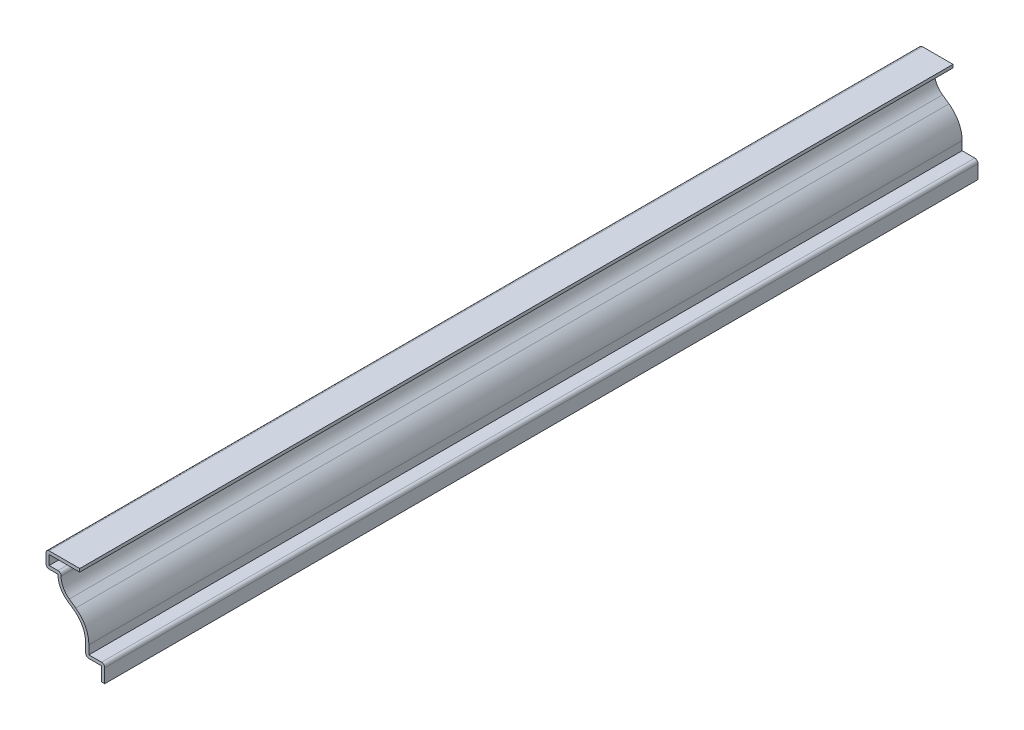
from build123d import *

# Parameters (mm, degrees)
EXTRUDE_THIN1_DEPTH = 349.25
FILLET1_R           = 1.27


with BuildPart() as part:
    # Sketch1 → Extrude-Thin1 (new body)
    with BuildSketch(Plane.XY):
        with BuildLine():
            Line((0, 0), (0, 5.55625))
            Line((0, 5.55625), (-6.35, 5.55625))
            Line((-6.35, 5.55625), (-6.35, 10.31875))
            ThreePointArc((-6.35, 10.31875), (-7.597327769, 15.43402449), (-11.059297297, 19.400966216))
            Line((-11.059297297, 19.400966216), (-13.654216216, 21.230452703))
            ThreePointArc((-13.654216216, 21.230452703), (-16.453819125, 24.438413231), (-17.4625, 28.575))
            Line((-17.4625, 28.575), (-22.225, 28.575))
            Line((-22.225, 28.575), (-22.225, 34.925))
            Line((-22.225, 34.925), (-8.73125, 34.925))
            Line((-8.73125, 34.925), (-8.73125, 33.655))
            Line((-8.73125, 33.655), (-20.955, 33.655))
            Line((-20.955, 33.655), (-20.955, 29.845))
            Line((-20.955, 29.845), (-16.087271104, 29.845))
            ThreePointArc((-16.087271104, 29.845), (-15.596279625, 25.600802309), (-12.922421622, 22.26842027))
            Line((-12.922421622, 22.26842027), (-10.327502703, 20.438933784))
            ThreePointArc((-10.327502703, 20.438933784), (-6.469879514, 16.018627289), (-5.08, 10.31875))
            Line((-5.08, 10.31875), (-5.08, 6.82625))
            Line((-5.08, 6.82625), (1.27, 6.82625))
            Line((1.27, 6.82625), (1.27, 0))
            Line((1.27, 0), (0, 0))
        make_face()
    extrude(amount=-EXTRUDE_THIN1_DEPTH)

    # Fillet1
    fillet1_edges = [part.edges().sort_by_distance(p)[0] for p in [
        (-16.087271104, 29.845, -174.625),
        (1.27, 6.82625, -174.625),
        (-6.35, 5.55625, -174.625),
        (-22.225, 28.575, -174.625),
        (-22.225, 34.925, -174.625),
    ]]
    fillet(fillet1_edges, radius=FILLET1_R)


solid = part.part
